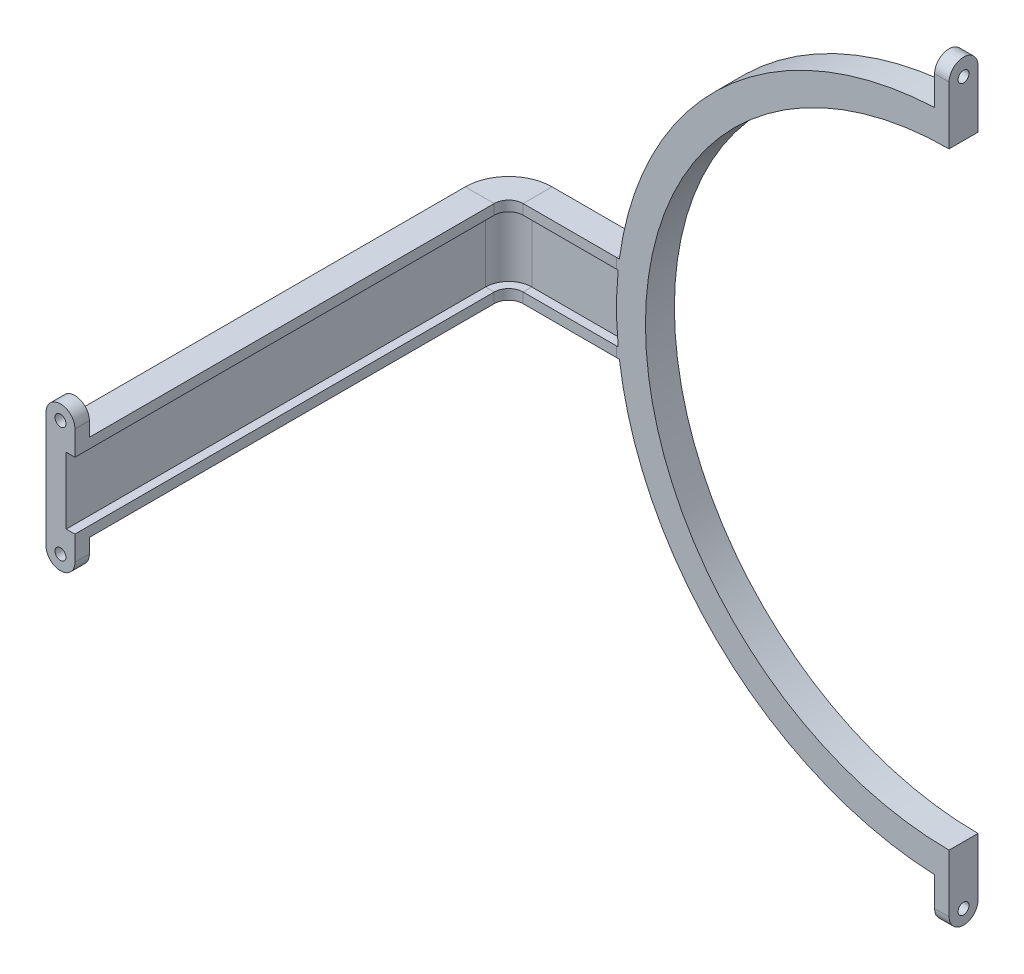
from build123d import *

# Parameters (mm, degrees)
SKETCH_1_R                = 115
SKETCH_1_R_2              = 105
EXTRUDE_1_DEPTH           = 5
SKETCH_4_R                = 2.5
CUT_EXTRUDE_1_DEPTH       = 33.934862746
EXTRUDE_2_DEPTH           = 5
HOLE_WIZARD_1_D           = 4.5
HOLE_WIZARD_1_CBORE_D     = 6
HOLE_WIZARD_1_CBORE_DEPTH = 3
SKETCH_9_R                = 2.25
SKETCH_9_R_2              = 1.9
EXTRUDE_3_DEPTH           = 5
EXTRUDE_4_DEPTH           = 5
HOLE_WIZARD_2_D           = 4.5
HOLE_WIZARD_2_CBORE_D     = 6
HOLE_WIZARD_2_CBORE_DEPTH = 3
SKETCH_13_R               = 2.25
SKETCH_13_R_2             = 1.9
EXTRUDE_5_DEPTH           = 5
SKETCH_14_W               = 562.038590931
SKETCH_14_H               = 462.09177453
CUT_EXTRUDE_4_DEPTH       = 163.29776757
SKETCH_15_W               = 637.223239982
SKETCH_15_H               = 375.31186697
CUT_EXTRUDE_5_DEPTH       = 202.710100717


with BuildPart() as part:
    # 草图1 → 凸台-拉伸1 (new body, symmetric)
    with BuildSketch(Plane.XY):
        Circle(SKETCH_1_R)
        Circle(SKETCH_1_R_2, mode=Mode.SUBTRACT)
    extrude(amount=EXTRUDE_1_DEPTH, both=True)

    # 扫描1: sweep along a path in 草图2
    with BuildLine(Plane(origin=(0, 0, 0), x_dir=(1, 0, 0), z_dir=(0, 1, 0))) as sweep_1_path:
        Line((-130, -355), (-156.694693778, -281.656931626))
        ThreePointArc((-156.694693778, -281.656931626), (-157.1458451, -279.97321197), (-157.29776757, -278.236730193))
        Line((-157.29776757, -278.236730193), (-157.29776757, -10))
        ThreePointArc((-157.29776757, -10), (-154.368835382, -2.928932188), (-147.29776757, 0))
        Line((-147.29776757, 0), (-115, 0))
        Line((-115, 0), (-106.681302201, 0))
    # 草图3 → 扫描1 (sweep)
    with BuildSketch(Plane(origin=(-130, 0, 355), x_dir=(0.939692621, 0, -0.342020143), z_dir=(0.342020143, 0, 0.939692621))):
        Polygon((-5, -15), (5, -15), (5, -11.5), (2, -11.5), (2, 11.5), (5, 11.5), (5, 15), (-5, 15), align=None)
    sweep_1 = sweep(path=sweep_1_path.line)

    # 草图4 → 切除-拉伸1 (cut, through all)
    with BuildSketch(Plane(origin=(-227.008304281, 0, 82.624265689), x_dir=(-0.342020143, 0, -0.939692621), z_dir=(0.939692621, 0, -0.342020143))):
        with Locations((-274.128261747, 6.75)):
            Circle(SKETCH_4_R)
        with Locations((-274.128261747, -6.75)):
            Circle(SKETCH_4_R)
    cut_extrude_1 = extrude(amount=-CUT_EXTRUDE_1_DEPTH, mode=Mode.SUBTRACT)

    # 镜向1: 扫描1, 切除-拉伸1 across plane
    add(sweep_1.mirror(Plane(origin=(0, 0, 0), x_dir=(0, 0, 1), z_dir=(1, 0, 0))))
    add(cut_extrude_1.mirror(Plane(origin=(0, 0, 0), x_dir=(0, 0, 1), z_dir=(1, 0, 0))), mode=Mode.SUBTRACT)

    # 草图6 → 凸台-拉伸2 (add, symmetric)
    with BuildSketch(Plane(origin=(0, 0, 0), x_dir=(0, 0, -1), z_dir=(1, 0, 0))):
        with BuildLine():
            Line((-5, 115), (-5, 125))
            ThreePointArc((-5, 125), (0, 130), (5, 125))
            Line((5, 125), (5, 115))
            Line((5, 115), (5, 112.136445143))
            Line((5, 112.136445143), (-5, 112.136445143))
            Line((-5, 112.136445143), (-5, 115))
        make_face()
    extrude_2 = extrude(amount=EXTRUDE_2_DEPTH, both=True)

    # 镜向2: 凸台-拉伸2 across plane
    add(extrude_2.mirror(Plane.ZX))

    # 孔1 (through all)
    with Locations(Plane(origin=(5, 0, 0), x_dir=(0, 0, -1), z_dir=(1, 0, 0))):
        with Locations((0, 124.156343107), (0, -125)):
            CounterBoreHole(HOLE_WIZARD_1_D / 2, HOLE_WIZARD_1_CBORE_D / 2, HOLE_WIZARD_1_CBORE_DEPTH)

    # 草图9 → 凸台-拉伸3 (add)
    with BuildSketch(Plane.ZY.offset(5)):
        with Locations((0, 124.156343107)):
            Circle(SKETCH_9_R)
        with Locations((0, 124.156343107)):
            Circle(SKETCH_9_R_2, mode=Mode.SUBTRACT)
        with Locations((0, -125)):
            Circle(SKETCH_9_R)
        with Locations((0, -125)):
            Circle(SKETCH_9_R_2, mode=Mode.SUBTRACT)
    extrude(amount=-EXTRUDE_3_DEPTH)

    # 草图10 → 凸台-拉伸4 (add, symmetric)
    with BuildSketch(Plane.XY.offset(155)):
        with BuildLine():
            Line((-162.29776757, 15), (-152.29776757, 15))
            Line((-152.29776757, 15), (-152.29776757, 20))
            ThreePointArc((-152.29776757, 20), (-157.29776757, 25), (-162.29776757, 20))
            Line((-162.29776757, 20), (-162.29776757, 15))
        make_face()
        with BuildLine():
            Line((-152.29776757, -15), (-152.29776757, -20))
            ThreePointArc((-152.29776757, -20), (-157.29776757, -25), (-162.29776757, -20))
            Line((-162.29776757, -20), (-162.29776757, -15))
            Line((-162.29776757, -15), (-152.29776757, -15))
        make_face()
        with BuildLine():
            Line((162.29776757, -15), (152.29776757, -15))
            Line((152.29776757, -15), (152.29776757, -20))
            ThreePointArc((152.29776757, -20), (157.29776757, -25), (162.29776757, -20))
            Line((162.29776757, -20), (162.29776757, -15))
        make_face()
        with BuildLine():
            Line((152.29776757, 15), (152.29776757, 20))
            ThreePointArc((152.29776757, 20), (157.29776757, 25), (162.29776757, 20))
            Line((162.29776757, 20), (162.29776757, 15))
            Line((162.29776757, 15), (152.29776757, 15))
        make_face()
    extrude(amount=EXTRUDE_4_DEPTH, both=True)

    # 孔2 (through all)
    with Locations(Plane.XY.offset(160)):
        with Locations((-157.29776757, 20), (-157.29776757, -20), (157.29776757, 20), (157.29776757, -20)):
            CounterBoreHole(HOLE_WIZARD_2_D / 2, HOLE_WIZARD_2_CBORE_D / 2, HOLE_WIZARD_2_CBORE_DEPTH)

    # 草图13 → 凸台-拉伸5 (add)
    with BuildSketch(Plane(origin=(0, 0, 150), x_dir=(-1, 0, 0), z_dir=(0, 0, -1))):
        with Locations((-157.29776757, 20)):
            Circle(SKETCH_13_R)
        with Locations((-157.29776757, 20)):
            Circle(SKETCH_13_R_2, mode=Mode.SUBTRACT)
        with Locations((-157.29776757, -20)):
            Circle(SKETCH_13_R)
        with Locations((-157.29776757, -20)):
            Circle(SKETCH_13_R_2, mode=Mode.SUBTRACT)
        with Locations((157.29776757, -20)):
            Circle(SKETCH_13_R)
        with Locations((157.29776757, -20)):
            Circle(SKETCH_13_R_2, mode=Mode.SUBTRACT)
        with Locations((157.29776757, 20)):
            Circle(SKETCH_13_R)
        with Locations((157.29776757, 20)):
            Circle(SKETCH_13_R_2, mode=Mode.SUBTRACT)
    extrude(amount=-EXTRUDE_5_DEPTH)

    # 草图14 → 切除-拉伸4 (cut, through all)
    with BuildSketch(Plane(origin=(0, 0, 0), x_dir=(0, 0, -1), z_dir=(1, 0, 0))):
        with Locations((-153.139864812, -31.152254463)):
            Rectangle(SKETCH_14_W, SKETCH_14_H)
    extrude(amount=CUT_EXTRUDE_4_DEPTH, mode=Mode.SUBTRACT)

    # 草图15 → 切除-拉伸5 (cut, through all)
    with BuildSketch(Plane.XY.offset(155)):
        Rectangle(SKETCH_15_W, SKETCH_15_H)
    extrude(amount=CUT_EXTRUDE_5_DEPTH, mode=Mode.SUBTRACT)


solid = part.part
